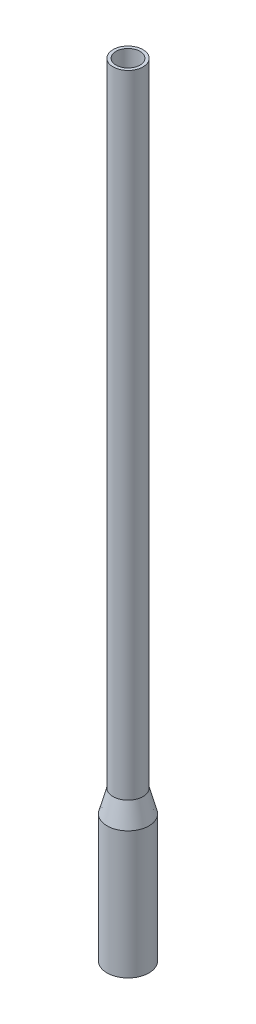
from build123d import *


with BuildPart() as part:
    # Sketch1 → Revolve1 (revolve)
    with BuildSketch(Plane.XY):
        Polygon((-70, -74.641016151), (-70, -500), (-60, -500), (-60, -75.957541127), (-40, -1.316524976), (-40, 2110), (-50, 2110), (-50, 0), align=None)
    revolve(axis=Axis((0, 0, 0), (0, 1, 0)))


solid = part.part
